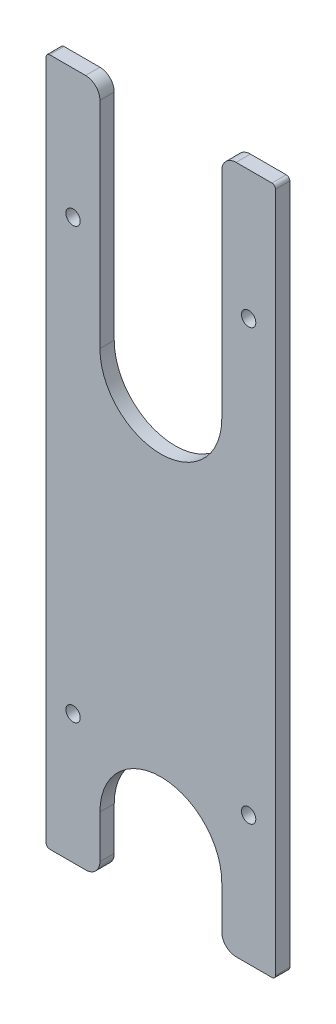
from build123d import *

# Parameters (mm, degrees)
BOSS_EXTRUDE1_DEPTH            = 6.35
F_1_4_0_2500_DOWEL_HOLE1_D     = 6.35
F_1_4_0_2500_DOWEL_HOLE1_DEPTH = 6.35
FILLET1_R                      = 6.35
FILLET2_R                      = 1.5875


with BuildPart() as part:
    # Sketch1 → Boss-Extrude1 (new body)
    with BuildSketch(Plane.XY):
        with BuildLine():
            Line((-26.9875, 50.8), (-26.9875, 152.4))
            Line((-26.9875, 152.4), (-50.8, 152.4))
            Line((-50.8, 152.4), (-50.8, -152.4))
            Line((-50.8, -152.4), (-26.9875, -152.4))
            Line((-26.9875, -152.4), (-26.9875, -127))
            ThreePointArc((-26.9875, -127), (0, -100.0125), (26.9875, -127))
            Line((26.9875, -127), (26.9875, -152.4))
            Line((26.9875, -152.4), (50.8, -152.4))
            Line((50.8, -152.4), (50.8, 152.4))
            Line((50.8, 152.4), (26.9875, 152.4))
            Line((26.9875, 152.4), (26.9875, 50.8))
            ThreePointArc((26.9875, 50.8), (0, 23.8125), (-26.9875, 50.8))
        make_face()
    extrude(amount=BOSS_EXTRUDE1_DEPTH)

    # 1/4 (0.2500) Dowel Hole1
    with Locations(Plane.XY.offset(6.35)):
        with Locations((-38.89375, 95.25), (38.89375, 95.25), (38.89375, -95.25), (-38.89375, -95.25)):
            Hole(F_1_4_0_2500_DOWEL_HOLE1_D / 2, depth=F_1_4_0_2500_DOWEL_HOLE1_DEPTH)

    # Fillet1
    fillet1_edges = [part.edges().sort_by_distance(p)[0] for p in [
        (26.9875, -152.4, 3.175),
        (-26.9875, -152.4, 3.175),
        (-26.9875, 152.4, 3.175),
        (26.9875, 152.4, 3.175),
    ]]
    fillet(fillet1_edges, radius=FILLET1_R)

    # Fillet2
    fillet2_edges = [part.edges().sort_by_distance(p)[0] for p in [
        (-50.8, -152.4, 3.175),
        (-50.8, 152.4, 3.175),
        (50.8, 152.4, 3.175),
        (50.8, -152.4, 3.175),
    ]]
    fillet(fillet2_edges, radius=FILLET2_R)


solid = part.part
